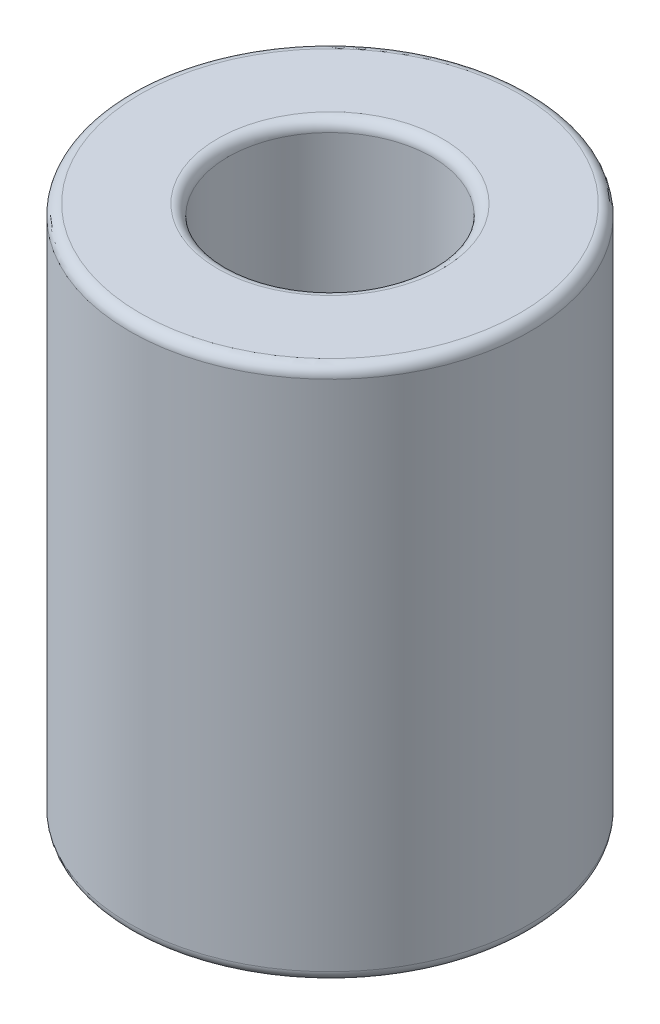
from build123d import *

# Parameters (mm, degrees)
ESQUISSE2_R        = 9.525
ESQUISSE2_R_2      = 4.8514
BOSS_EXTRU_1_DEPTH = 12.7
CONG_2_R           = 0.5


with BuildPart() as part:
    # Esquisse2 → Boss.-Extru.1 (new body, symmetric)
    with BuildSketch(Plane(origin=(0, 0, 0), x_dir=(1, 0, 0), z_dir=(0, 1, 0))):
        Circle(ESQUISSE2_R)
        Circle(ESQUISSE2_R_2, mode=Mode.SUBTRACT)
    extrude(amount=BOSS_EXTRU_1_DEPTH, both=True)

    # Congé2
    cong_2_edges = [part.edges().sort_by_distance(p)[0] for p in [
        (-9.525, -12.7, 0),
        (-9.525, 12.7, 0),
        (-4.8514, -12.7, 0),
        (-4.8514, 12.7, 0),
    ]]
    fillet(cong_2_edges, radius=CONG_2_R)


solid = part.part
